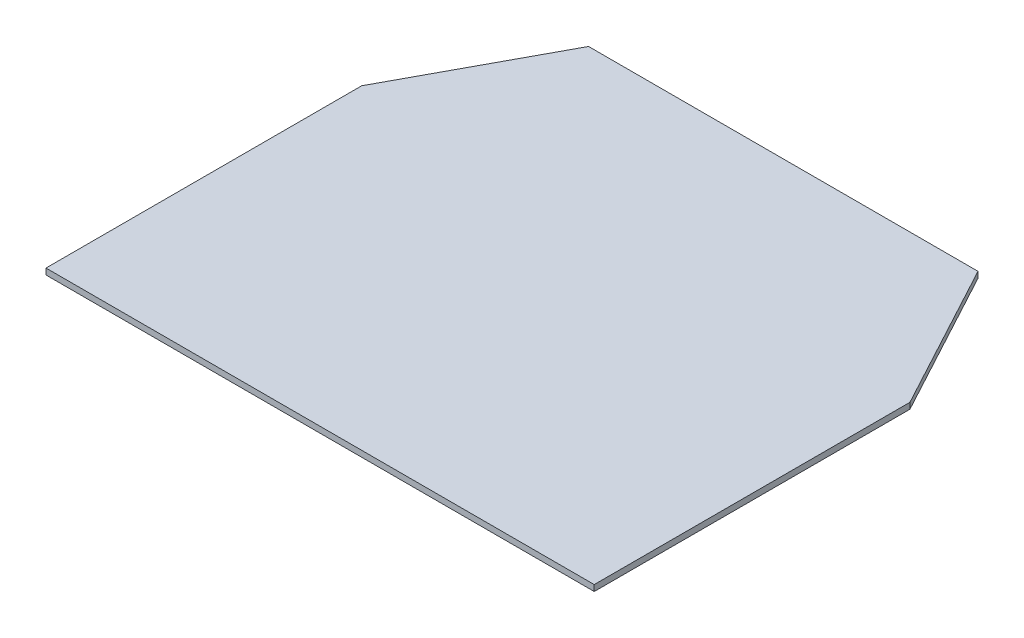
from build123d import *

# Parameters (mm, degrees)
BOSS_EXTRUDE1_DEPTH = 3.2


with BuildPart() as part:
    # Sketch1 → Boss-Extrude1 (new body)
    with BuildSketch(Plane(origin=(0, 0, 0), x_dir=(1, 0, 0), z_dir=(0, 1, 0))):
        Polygon((0, 0), (0, 167), (42, 245), (248, 245), (290, 167), (290, 0), align=None)
    extrude(amount=BOSS_EXTRUDE1_DEPTH)


solid = part.part
